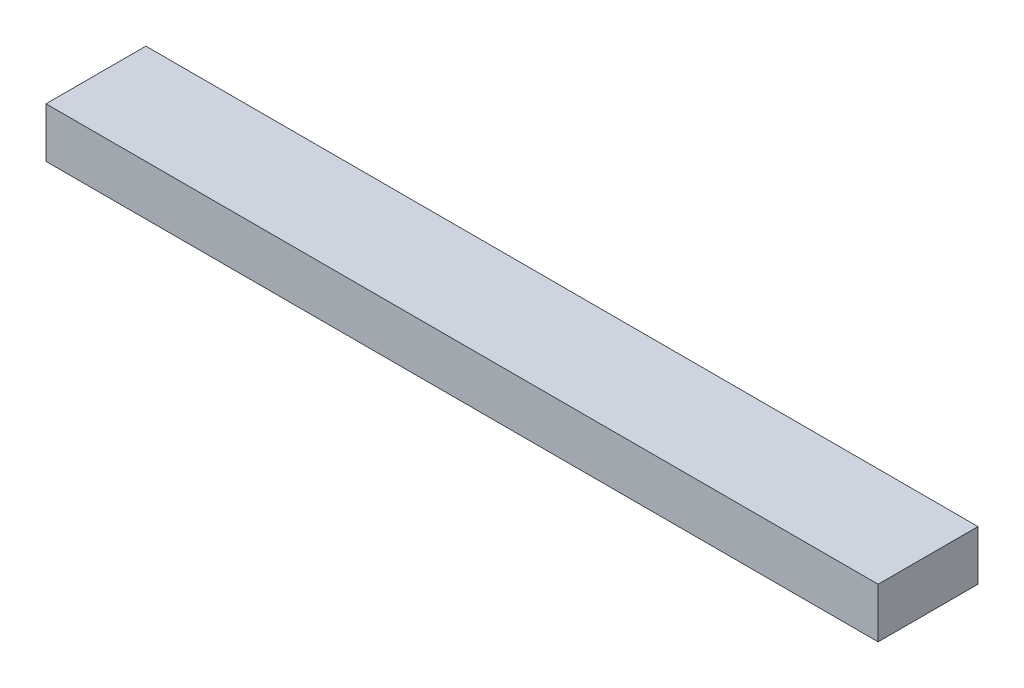
from build123d import *

# Parameters (mm, degrees)
SKETCH_1_W      = 250
SKETCH_1_H      = 30
EXTRUDE_1_DEPTH = 15


with BuildPart() as part:
    # Эскиз1 → Бобышка-Вытянуть1 (new body)
    with BuildSketch(Plane(origin=(0, 0, 0), x_dir=(1, 0, 0), z_dir=(0, 1, 0))):
        with Locations((125, 15)):
            Rectangle(SKETCH_1_W, SKETCH_1_H)
    extrude(amount=EXTRUDE_1_DEPTH)


solid = part.part
